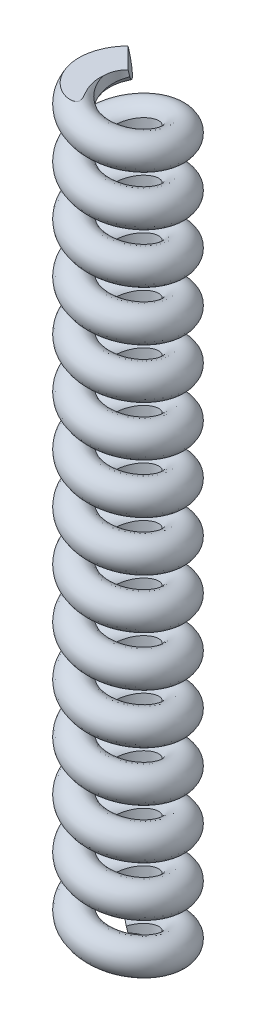
from build123d import *

# Parameters (mm, degrees)
SWEEP1_PITCH            = 4.154992
SWEEP1_HEIGHT           = 62.32488
SWEEP1_RADIUS           = 3.175
SWEEP1_START_ANGLE      = -135
SWEEP1_PROFILE_R        = 1.27
SKETCH10_W              = 25.003337153
SKETCH10_H              = 23.767682809
SKETCH10_W_2            = 16.112477969
SKETCH10_H_2            = 4.696995423
TOPANDBOTTOM_DEPTH      = 64.87825893
TOPANDBOTTOM_DEPTH_BACK = 64.87825893
SKETCH13_R              = 2.019009335
CENTRALHOLE_DEPTH       = 63.641094912
CENTRALHOLE_DEPTH_BACK  = 63.641094912


with BuildPart() as part:
    # Sweep1: sweep along a helix
    with BuildLine() as sweep1_path:
        add(Helix(SWEEP1_PITCH, SWEEP1_HEIGHT, SWEEP1_RADIUS, center=(0, 0, 0), direction=(0, 1, 0), lefthand=True, mode=Mode.PRIVATE).rotate(Axis((0, 0, 0), (0, 1, 0)), SWEEP1_START_ANGLE))
    # Sweep1 profile (on start of the path) → Sweep1 (sweep)
    with BuildSketch(Plane(origin=(-2.24506403, 0, -2.24506403), x_dir=(0.7071067811865089, 0, 0.7071067811865861), z_dir=(0.6922511288852464, 0.2039037741541549, -0.6922511288851708))):
        Circle(SWEEP1_PROFILE_R)
    sweep(path=sweep1_path.line, is_frenet=True)

    # Sketch10 → TopandBottom (cut, two sides)
    with BuildSketch(Plane(origin=(0, 0, 0), x_dir=(0, 0, -1), z_dir=(1, 0, 0))) as topandbottom_sk:
        with Locations((2.245064031, 74.208721405)):
            Rectangle(SKETCH10_W, SKETCH10_H)
        with Locations((0.75508272, -2.348497712)):
            Rectangle(SKETCH10_W_2, SKETCH10_H_2)
    extrude(amount=TOPANDBOTTOM_DEPTH, mode=Mode.SUBTRACT)
    extrude(topandbottom_sk.sketch, amount=-TOPANDBOTTOM_DEPTH_BACK, mode=Mode.SUBTRACT)

    # Sketch13 → CentralHole (cut, two sides)
    with BuildSketch(Plane(origin=(0, 0, 0), x_dir=(1, 0, 0), z_dir=(0, 1, 0))) as centralhole_sk:
        Circle(SKETCH13_R)
    extrude(amount=CENTRALHOLE_DEPTH, mode=Mode.SUBTRACT)
    extrude(centralhole_sk.sketch, amount=-CENTRALHOLE_DEPTH_BACK, mode=Mode.SUBTRACT)


solid = part.part
